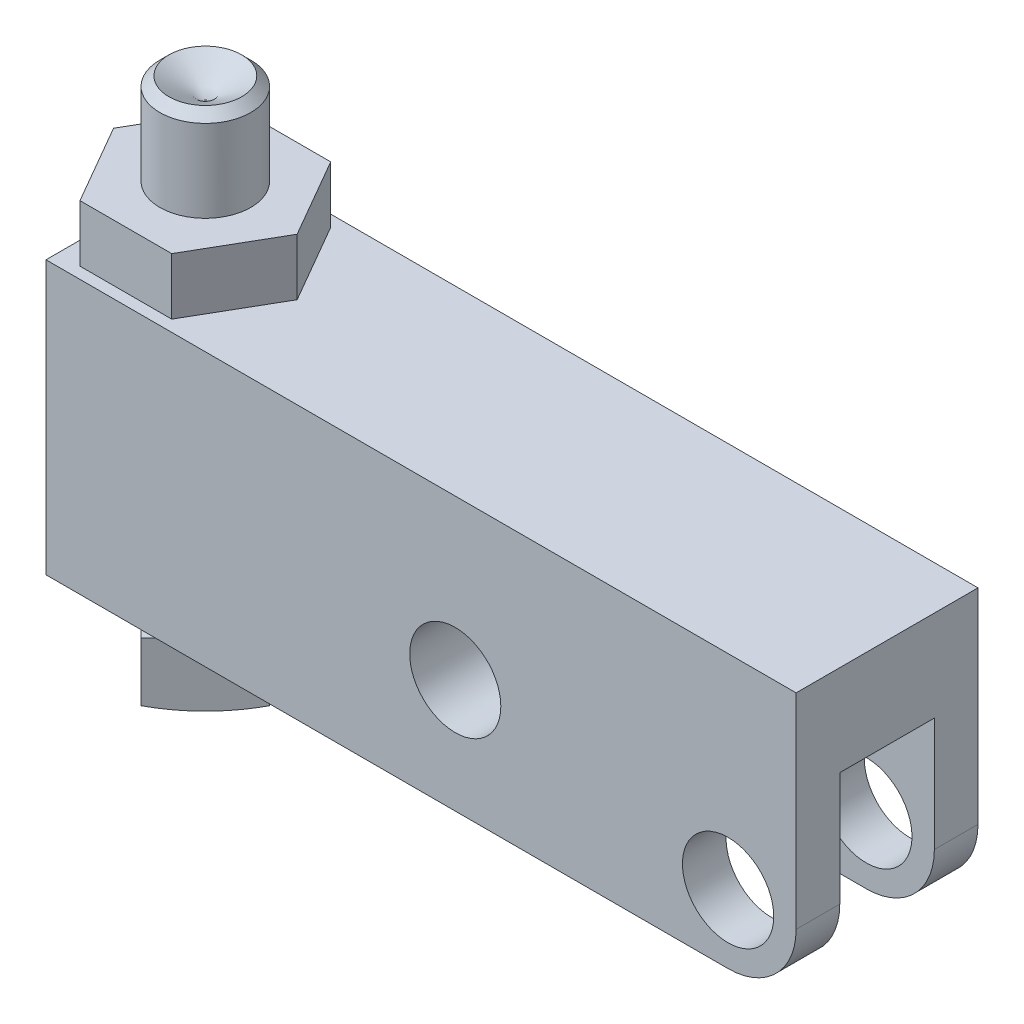
from build123d import *

# Parameters (mm, degrees)
SKETCH11_W         = 52.3748
SKETCH11_H         = 19.05
SKETCH11_R         = 3.1877
SKETCH11_R_2       = 3.18135
EXTRUDE3_DEPTH     = 6.35
CUT_EXTRUDE1_DEPTH = 12.7
FILLET1_R          = 4.7498
EXTRUDE4_DEPTH     = 3.9624
SKETCH15_R         = 10.473643108
CUT_EXTRUDE2_DEPTH = 5.7498


with BuildPart() as part:
    # Sketch11 → Extrude3 (new body, symmetric)
    with BuildSketch(Plane.XY):
        with Locations((-21.4376, 4.7752)):
            Rectangle(SKETCH11_W, SKETCH11_H)
        Circle(SKETCH11_R, mode=Mode.SUBTRACT)
        with Locations((-19.05, 3.175)):
            Circle(SKETCH11_R_2, mode=Mode.SUBTRACT)
    extrude(amount=EXTRUDE3_DEPTH, both=True)

    # Sketch12 → Cut-Extrude1 (cut)
    with BuildSketch(Plane.XZ.offset(4.7498)):
        with BuildLine():
            Line((-7.9502, 3.302), (4.7498, 3.302))
            Line((4.7498, 3.302), (4.7498, -3.302))
            Line((4.7498, -3.302), (-7.9502, -3.302))
            ThreePointArc((-7.9502, -3.302), (-11.2522, 0), (-7.9502, 3.302))
        make_face()
    extrude(amount=-CUT_EXTRUDE1_DEPTH, mode=Mode.SUBTRACT)

    # Fillet1
    fillet1_edges = [part.edges().sort_by_distance(p)[0] for p in [
        (4.7498, -4.7498, -4.826),
        (4.7498, -4.7498, 4.826),
    ]]
    fillet(fillet1_edges, radius=FILLET1_R)

    # Sketch13 → Extrude4 (add)
    with BuildSketch(Plane(origin=(0, 14.3002, 0), x_dir=(1, 0, 0), z_dir=(0, 1, 0))):
        Polygon((-36.441327482, 0), (-39.645563741, 5.5499), (-46.054036259, 5.5499), (-49.258272518, 0), (-46.054036259, -5.5499), (-39.645563741, -5.5499), align=None)
    extrude(amount=EXTRUDE4_DEPTH)

    # Sketch14 → Revolve2 (revolve)
    with BuildSketch(Plane.XY):
        with BuildLine():
            Line((-42.8498, 23.171530316), (-45.3898, 24.638))
            Line((-45.3898, 24.638), (-46.0248, 24.003))
            Line((-46.0248, 24.003), (-46.0248, -7.112))
            Line((-46.0248, -7.112), (-53.323443108, -7.112))
            Line((-53.323443108, -7.112), (-53.323443108, -7.874))
            ThreePointArc((-53.323443108, -7.874), (-48.453364687, -10.831121998), (-42.8498, -11.8618))
            Line((-42.8498, -11.8618), (-42.8498, 23.171530316))
        make_face()
    revolve(axis=Axis((-42.8498, 26.585218564, 0), (0, -1, 0)))

    # Sketch15 → Cut-Extrude2 (cut, through all)
    with BuildSketch(Plane(origin=(0, -7.112, 0), x_dir=(1, 0, 0), z_dir=(0, 1, 0))):
        with Locations((-42.8498, 0)):
            Circle(SKETCH15_R)
        Polygon((-42.8498, 4.490128061), (-47.339928061, 0), (-42.8498, -4.490128061), (-38.359671939, 0), align=None, mode=Mode.SUBTRACT)
    extrude(amount=-CUT_EXTRUDE2_DEPTH, mode=Mode.SUBTRACT)


solid = part.part
